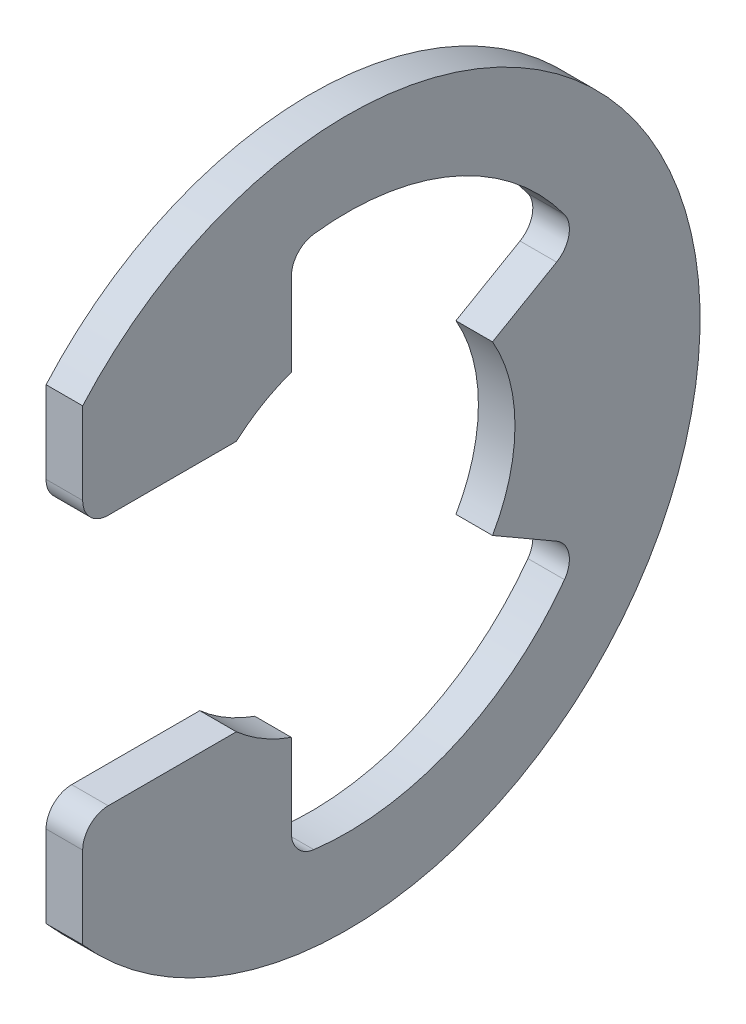
from build123d import *

# Parameters (mm, degrees)
EXTRUDE1_DEPTH = 0.5334
FILLET1_R      = 0.74676


with BuildPart() as part:
    # Sketch1 → Extrude1 (new body, symmetric)
    with BuildSketch(Plane(origin=(0, 0, 0), x_dir=(0, 0, -1), z_dir=(1, 0, 0))):
        with BuildLine():
            Line((-3.234100259, 3.667125), (-7.71525, 3.667125))
            Line((-7.71525, 3.667125), (-7.71525, 6.804210934))
            ThreePointArc((-7.71525, 6.804210934), (10.287, 0), (-7.71525, -6.804210934))
            Line((-7.71525, -6.804210934), (-7.71525, -3.667125))
            Line((-7.71525, -3.667125), (-3.234100259, -3.667125))
            ThreePointArc((-3.234100259, -3.667125), (-2.477226692, -4.215513986), (-1.629833333, -4.609864809))
            Line((-1.629833333, -4.609864809), (-1.629833333, -7.661594982))
            ThreePointArc((-1.629833333, -7.661594982), (3.185395471, -7.156091814), (6.783604924, -3.916516129))
            Line((6.783604924, -3.916516129), (4.234431212, -2.44475))
            ThreePointArc((4.234431212, -2.44475), (4.8895, 0), (4.234431212, 2.44475))
            Line((4.234431212, 2.44475), (6.783604924, 3.916516129))
            ThreePointArc((6.783604924, 3.916516129), (3.185395471, 7.156091814), (-1.629833333, 7.661594982))
            Line((-1.629833333, 7.661594982), (-1.629833333, 4.609864809))
            ThreePointArc((-1.629833333, 4.609864809), (-2.477226692, 4.215513986), (-3.234100259, 3.667125))
        make_face()
    extrude(amount=EXTRUDE1_DEPTH, both=True)

    # Fillet1
    fillet1_edges = [part.edges().sort_by_distance(p)[0] for p in [
        (0, -3.667125, 7.71525),
        (0, -7.661594982, 1.629833333),
        (0, -3.916516129, -6.783604924),
        (0, 3.916516129, -6.783604924),
        (0, 7.661594982, 1.629833333),
        (0, 3.667125, 7.71525),
    ]]
    fillet(fillet1_edges, radius=FILLET1_R)


solid = part.part
